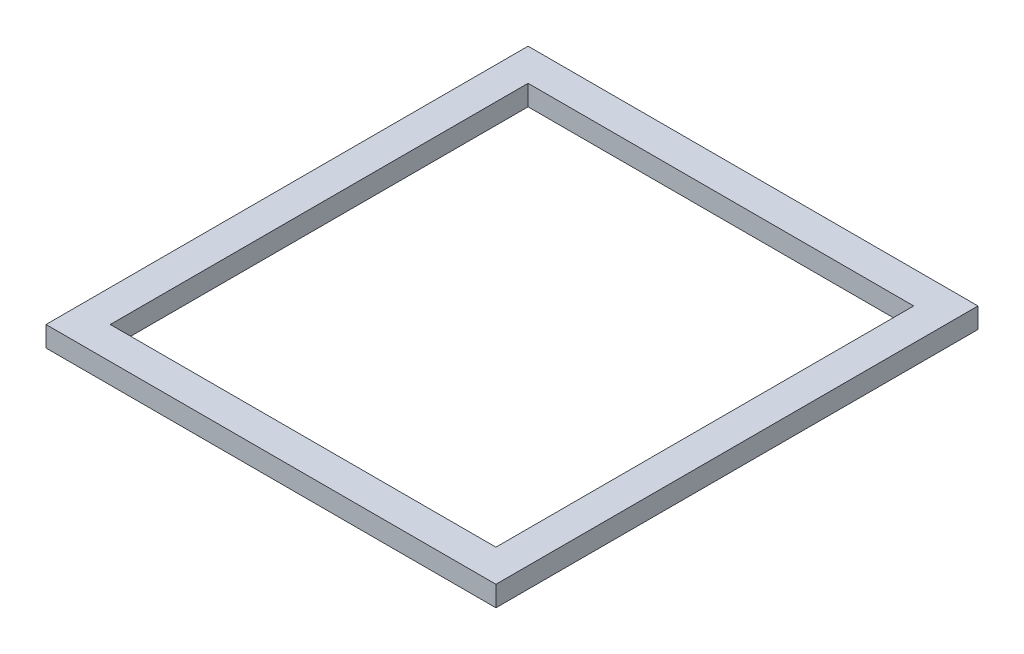
from build123d import *

# Parameters (mm, degrees)
SKETCH1_W           = 140
SKETCH1_H           = 150
SKETCH1_W_2         = 120
SKETCH1_H_2         = 130
BOSS_EXTRUDE1_DEPTH = 6.35


with BuildPart() as part:
    # Sketch1 → Boss-Extrude1 (new body)
    with BuildSketch(Plane(origin=(0, 0, 0), x_dir=(1, 0, 0), z_dir=(0, 1, 0))):
        with Locations((60, 65)):
            Rectangle(SKETCH1_W, SKETCH1_H)
        with Locations((60, 65)):
            Rectangle(SKETCH1_W_2, SKETCH1_H_2, mode=Mode.SUBTRACT)
    extrude(amount=BOSS_EXTRUDE1_DEPTH)


solid = part.part
